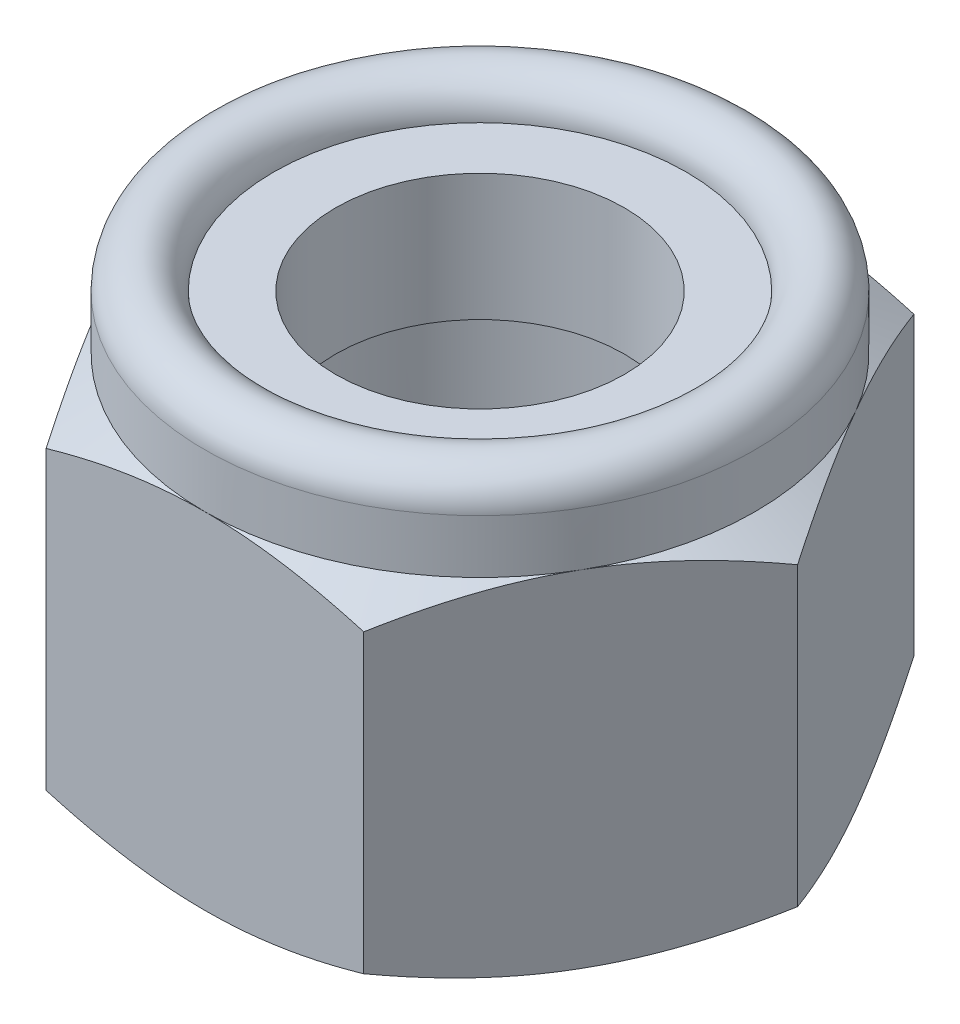
from build123d import *

# Parameters (mm, degrees)
ESQUISSE2_OUTSIDE_W     = 16.754
ESQUISSE2_OUTSIDE_H     = 16.754
ENL_V_MAT_EXTRU_2_DEPTH = 7.3000001


with BuildPart() as part:
    # Esquisse1 → Base-Révolution (revolve)
    with BuildSketch(Plane.XY, mode=Mode.PRIVATE) as base_r_volution_sk:
        with BuildLine():
            Line((3, 5.800000004), (3.499999996, 5.800000004))
            Line((3.499999996, 5.800000004), (3.499999996, 4.33246532))
            Line((3.499999996, 4.33246532), (2.5, 4.064516129))
            Line((2.5, 4.064516129), (2.5, 0))
            Line((2.5, 0), (4, 0))
            Line((4, 0), (5.656854249, 0.956585264))
            Line((5.656854249, 0.956585264), (5.656854249, 4.064516129))
            Line((5.656854249, 4.064516129), (3.999999993, 5.02110138))
            Line((3.999999993, 5.02110138), (3.999999993, 5.800000004))
            ThreePointArc((3.999999993, 5.800000004), (3.499999996, 6.3), (3, 5.800000004))
        make_face()
    revolve(base_r_volution_sk.sketch.rotate(Axis((0, 0, 0), (0, 1, 0)), 90), axis=Axis((0, 0, 0), (0, 1, 0)))  # turned: the seam where the file's is

    # Esquisse2 outside → Enlèv. mat.-Extru.2 (cut, through all)
    with BuildSketch(Plane(origin=(0, 0, 0), x_dir=(1, 0, 0), z_dir=(0, 1, 0))):
        Rectangle(ESQUISSE2_OUTSIDE_W, ESQUISSE2_OUTSIDE_H)
        Polygon((-2.309401077, 4), (2.309401077, 4), (4.618802154, 0), (2.309401077, -4), (-2.309401077, -4), (-4.618802154, 0), align=None, mode=Mode.SUBTRACT)
    extrude(amount=ENL_V_MAT_EXTRU_2_DEPTH, mode=Mode.SUBTRACT)

    # Esquisse4 → Boss.-Révol.1 (revolve)
    with BuildSketch(Plane.XY, mode=Mode.PRIVATE) as boss_r_vol_1_sk:
        Polygon((2.1, 3.957336452), (2.1, 5.800000004), (3.499999996, 5.800000004), (3.499999996, 4.33246532), align=None)
    revolve(boss_r_vol_1_sk.sketch.rotate(Axis((0, 5.02110138, 0), (0, -1, 0)), 270), axis=Axis((0, 5.02110138, 0), (0, -1, 0)))  # turned: the seam where the file's is


solid = part.part
